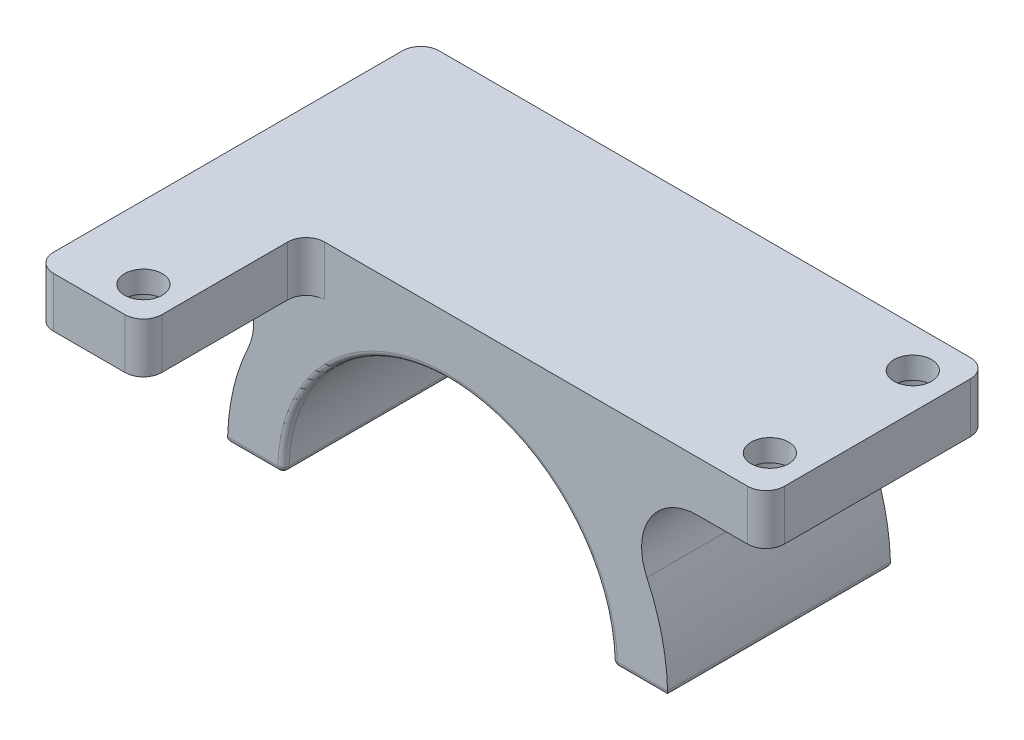
from build123d import *

# Parameters (mm, degrees)
SKETCH1_R           = 39.5
BOSS_EXTRUDE1_DEPTH = 40
CUT_EXTRUDE2_DEPTH  = 41
CUT_EXTRUDE3_DEPTH  = 41
FILLET2_R           = 1
SKETCH6_W           = 114.3
SKETCH6_H           = 9
BOSS_EXTRUDE2_DEPTH = 40
FILLET6_R           = 10
CUT_EXTRUDE4_REACH  = 42
SKETCH9_R           = 3.3782
SKETCH11_W          = 31.75
SKETCH11_H          = 9
BOSS_EXTRUDE3_DEPTH = 29.21
SKETCH4_W           = 3.002871012
SKETCH4_H           = 30
FILLET7_R           = 3.302
SKETCH13_R          = 5.08
CUT_EXTRUDE6_DEPTH  = 5.08
SKETCH15_R          = 3.3782
CUT_EXTRUDE8_DEPTH  = 10
SKETCH16_R          = 5.08
CUT_EXTRUDE9_DEPTH  = 5.08
SKETCH17_W          = 36.586278343
SKETCH17_H          = 70.835632368
CUT_EXTRUDE10_DEPTH = 10
FILLET8_R           = 3.302


with BuildPart() as part:
    # Sketch1 → Boss-Extrude1 (new body)
    with BuildSketch(Plane.XY):
        Circle(SKETCH1_R)
    extrude(amount=BOSS_EXTRUDE1_DEPTH)

    # Sketch2 → Cut-Extrude2 (cut, through all)
    with BuildSketch(Plane(origin=(0, 0, 0), x_dir=(-1, 0, 0), z_dir=(0, 0, -1))):
        with BuildLine():
            Line((-39.5, 0), (39.5, 0))
            ThreePointArc((39.5, 0), (0, -39.5), (-39.5, 0))
        make_face()
    extrude(amount=-CUT_EXTRUDE2_DEPTH, mode=Mode.SUBTRACT)

    # Sketch3 → Cut-Extrude3 (cut, through all)
    with BuildSketch(Plane(origin=(0, 0, 0), x_dir=(-1, 0, 0), z_dir=(0, 0, -1))):
        with BuildLine():
            Line((-29.5, 0), (29.5, 0))
            ThreePointArc((29.5, 0), (0, 29.5), (-29.5, 0))
        make_face()
    extrude(amount=-CUT_EXTRUDE3_DEPTH, mode=Mode.SUBTRACT)

    # Fillet2
    fillet2_edges = [part.edges().sort_by_distance(p)[0] for p in [
        (-34.5, 0, 0),
        (-34.5, 0, 40),
        (0, 29.5, 40),
        (29.5, 0, 20),
        (-29.5, 0, 20),
        (0, 29.5, 0),
        (-39.5, 0, 20),
        (34.5, 0, 0),
        (39.5, 0, 20),
        (34.5, 0, 40),
    ]]
    fillet(fillet2_edges, radius=FILLET2_R)

    # Sketch6 → Boss-Extrude2 (add)
    with BuildSketch(Plane(origin=(0, 0, 0), x_dir=(-1, 0, 0), z_dir=(0, 0, -1))):
        with Locations((0, 35.5)):
            Rectangle(SKETCH6_W, SKETCH6_H)
    extrude(amount=-BOSS_EXTRUDE2_DEPTH)

    # Fillet6
    fillet6_edges = [part.edges().sort_by_distance(p)[0] for p in [
        (-24.47958333, 31, 20),
        (24.47958333, 31, 20),
    ]]
    fillet(fillet6_edges, radius=FILLET6_R)

    # Sketch9 → Cut-Extrude4 (cut, up to next)
    with BuildSketch(Plane(origin=(0, 40, 0), x_dir=(1, 0, 0), z_dir=(0, 1, 0)), mode=Mode.PRIVATE) as cut_extrude4_sk1:
        with Locations((-50.677371465, -7.173)):
            Circle(SKETCH9_R)
    cut_extrude4_tool1 = extrude(cut_extrude4_sk1.sketch, amount=-CUT_EXTRUDE4_REACH, mode=Mode.PRIVATE) & part.part
    add(cut_extrude4_tool1.solids().sort_by_distance((-50.677371, 40, 7.173))[0], mode=Mode.SUBTRACT)
    # Sketch9 → Cut-Extrude4 (cut, up to next)
    with BuildSketch(Plane(origin=(0, 40, 0), x_dir=(1, 0, 0), z_dir=(0, 1, 0)), mode=Mode.PRIVATE) as cut_extrude4_sk2:
        with Locations((-50.677371465, -32.827)):
            Circle(SKETCH9_R)
    cut_extrude4_tool2 = extrude(cut_extrude4_sk2.sketch, amount=-CUT_EXTRUDE4_REACH, mode=Mode.PRIVATE) & part.part
    add(cut_extrude4_tool2.solids().sort_by_distance((-50.677371, 40, 32.827))[0], mode=Mode.SUBTRACT)

    # Sketch11 → Boss-Extrude3 (add)
    with BuildSketch(Plane.XY.offset(40)):
        with Locations((41.275, 35.5)):
            Rectangle(SKETCH11_W, SKETCH11_H)
    extrude(amount=BOSS_EXTRUDE3_DEPTH)

    # Sketch4 → Cut-Revolve1 (revolve, cut)
    with BuildSketch(Plane.XZ):
        with Locations((34.48557529, 20)):
            Rectangle(SKETCH4_W, SKETCH4_H)
    revolve(axis=Axis((0, 0, 0), (0, 0, 1)), mode=Mode.SUBTRACT)

    # Fillet7
    fillet7_edges = [part.edges().sort_by_distance(p)[0] for p in [
        (25.4, 35.5, 40),
        (25.4, 35.5, 69.21),
        (57.15, 35.5, 69.21),
        (-57.15, 35.5, 0),
        (57.15, 35.5, 0),
        (-57.15, 35.5, 40),
    ]]
    fillet(fillet7_edges, radius=FILLET7_R)

    # Sketch13 → Cut-Extrude6 (cut)
    with BuildSketch(Plane.XZ.offset(-31)):
        with Locations((-50.677371465, 32.827)):
            Circle(SKETCH13_R)
        with Locations((-50.677371465, 7.173)):
            Circle(SKETCH13_R)
    extrude(amount=-CUT_EXTRUDE6_DEPTH, mode=Mode.SUBTRACT)

    # Sketch15 → Cut-Extrude8 (cut, through all)
    with BuildSketch(Plane.XZ.offset(-31)):
        with Locations((31.75, 62.86)):
            Circle(SKETCH15_R)
    extrude(amount=-CUT_EXTRUDE8_DEPTH, mode=Mode.SUBTRACT)

    # Sketch16 → Cut-Extrude9 (cut)
    with BuildSketch(Plane.XZ.offset(-31)):
        with Locations((31.75, 62.86)):
            Circle(SKETCH16_R)
    extrude(amount=-CUT_EXTRUDE9_DEPTH, mode=Mode.SUBTRACT)

    # Sketch17 → Cut-Extrude10 (cut, through all)
    with BuildSketch(Plane.XZ.offset(-31)):
        with Locations((63.117797564, 35.417816184)):
            Rectangle(SKETCH17_W, SKETCH17_H)
    extrude(amount=-CUT_EXTRUDE10_DEPTH, mode=Mode.SUBTRACT)

    # Fillet8
    fillet8_edges = [part.edges().sort_by_distance(p)[0] for p in [
        (44.824658392, 35.5, 69.21),
        (44.824658392, 35.5, 0),
    ]]
    fillet(fillet8_edges, radius=FILLET8_R)


with BuildPart() as body_2:
    # Mirror8: mirrored copy
    add(part.part.mirror(Plane(origin=(-57.15, 40, 154.653783191), x_dir=(0, 0, 1), z_dir=(-1, 0, 0))))


solid = body_2.part
